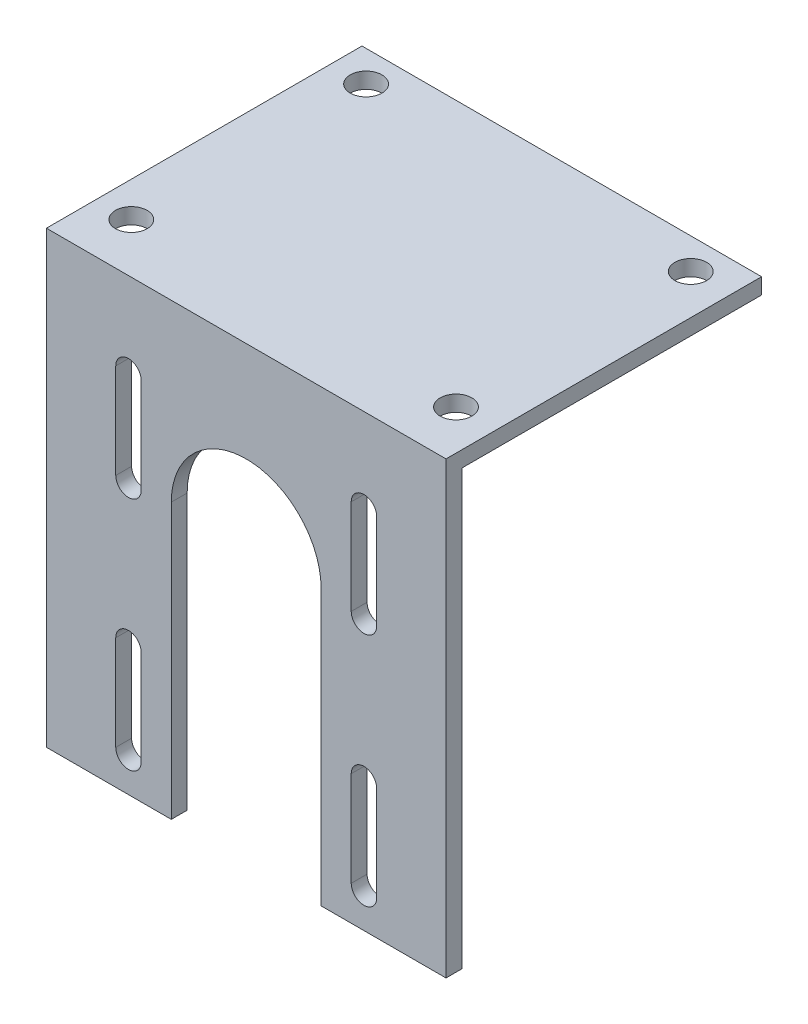
from build123d import *

# Parameters (mm, degrees)
SKETCH1_W           = 80
SKETCH1_H           = 100
BOSS_EXTRUDE1_DEPTH = 3.175
CUT_EXTRUDE2_REACH  = 5.175
SKETCH4_W           = 80
SKETCH4_H           = 3.175
BOSS_EXTRUDE2_DEPTH = 60
SKETCH5_R           = 3.175
CUT_EXTRUDE3_DEPTH  = 3.175
SKETCH6_W           = 80
SKETCH6_H           = 10
CUT_EXTRUDE4_DEPTH  = 64.175


with BuildPart() as part:
    # Sketch1 → Boss-Extrude1 (new body)
    with BuildSketch(Plane.XY):
        with Locations((40, -50)):
            Rectangle(SKETCH1_W, SKETCH1_H)
        with BuildLine():
            Line((18.98, -16.93), (18.98, -35.93))
            ThreePointArc((18.98, -35.93), (16.43, -38.48), (13.88, -35.93))
            Line((13.88, -35.93), (13.88, -16.93))
            ThreePointArc((13.88, -16.93), (16.43, -14.38), (18.98, -16.93))
        make_face(mode=Mode.SUBTRACT)
        with BuildLine():
            Line((61.02, -16.93), (61.02, -35.93))
            ThreePointArc((61.02, -35.93), (63.57, -38.48), (66.12, -35.93))
            Line((66.12, -35.93), (66.12, -16.93))
            ThreePointArc((66.12, -16.93), (63.57, -14.38), (61.02, -16.93))
        make_face(mode=Mode.SUBTRACT)
        with BuildLine():
            Line((18.98, -83.07), (18.98, -64.07))
            ThreePointArc((18.98, -64.07), (16.43, -61.52), (13.88, -64.07))
            Line((13.88, -64.07), (13.88, -83.07))
            ThreePointArc((13.88, -83.07), (16.43, -85.62), (18.98, -83.07))
        make_face(mode=Mode.SUBTRACT)
        with BuildLine():
            Line((61.02, -83.07), (61.02, -64.07))
            ThreePointArc((61.02, -64.07), (63.57, -61.52), (66.12, -64.07))
            Line((66.12, -64.07), (66.12, -83.07))
            ThreePointArc((66.12, -83.07), (63.57, -85.62), (61.02, -83.07))
        make_face(mode=Mode.SUBTRACT)
    extrude(amount=BOSS_EXTRUDE1_DEPTH)

    # Sketch2 → Cut-Extrude2 (cut, up to next)
    with BuildSketch(Plane.XY.offset(3.175), mode=Mode.PRIVATE) as cut_extrude2_sk1:
        with BuildLine():
            Line((25, -35), (25, -100))
            Line((25, -100), (55, -100))
            Line((55, -100), (55, -35))
            ThreePointArc((55, -35), (40, -20), (25, -35))
        make_face()
    cut_extrude2_tool1 = extrude(cut_extrude2_sk1.sketch, amount=-CUT_EXTRUDE2_REACH, mode=Mode.PRIVATE) & part.part
    add(cut_extrude2_tool1.solids().sort_by_distance((40, -61.536522, 3.175))[0], mode=Mode.SUBTRACT)

    # Sketch4 → Boss-Extrude2 (add)
    with BuildSketch(Plane(origin=(0, 0, 0), x_dir=(-1, 0, 0), z_dir=(0, 0, -1))):
        with Locations((-40, -1.5875)):
            Rectangle(SKETCH4_W, SKETCH4_H)
    extrude(amount=BOSS_EXTRUDE2_DEPTH)

    # Sketch5 → Cut-Extrude3 (cut)
    with BuildSketch(Plane(origin=(0, 0, 0), x_dir=(1, 0, 0), z_dir=(0, 1, 0))):
        with Locations((7, 53.825)):
            Circle(SKETCH5_R)
        with Locations((7, 6.825)):
            Circle(SKETCH5_R)
        with Locations((72, 53.825)):
            Circle(SKETCH5_R)
        with Locations((72, 6.825)):
            Circle(SKETCH5_R)
    extrude(amount=-CUT_EXTRUDE3_DEPTH, mode=Mode.SUBTRACT)

    # Sketch6 → Cut-Extrude4 (cut, through all)
    with BuildSketch(Plane.XY.offset(3.175)):
        with Locations((40, -95)):
            Rectangle(SKETCH6_W, SKETCH6_H)
    extrude(amount=-CUT_EXTRUDE4_DEPTH, mode=Mode.SUBTRACT)


solid = part.part
